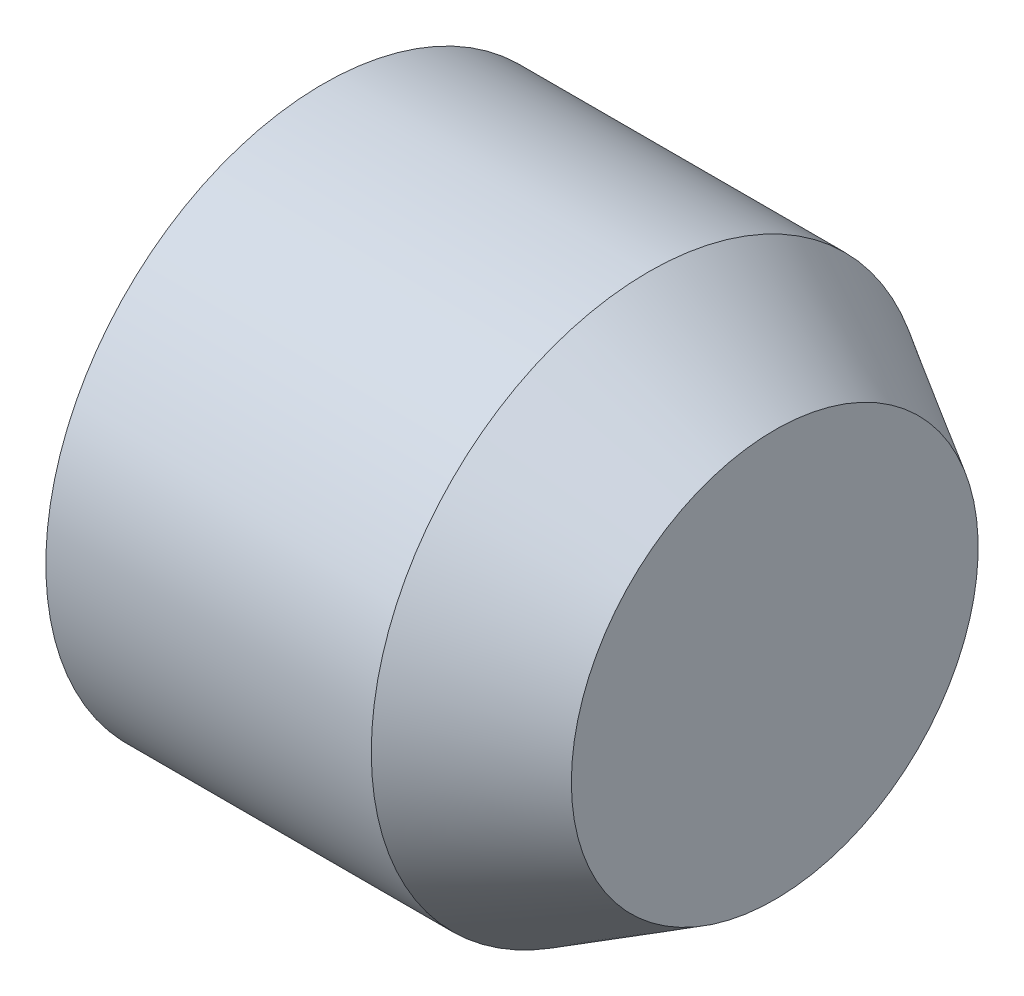
from build123d import *

# Parameters (mm, degrees)
SKETCH1_R           = 34.09
SKETCH1_R_2         = 32.09
BOSS_EXTRUDE1_DEPTH = 40
SWEEP1_PITCH        = 10
SWEEP1_HEIGHT       = 12.5
SWEEP1_RADIUS       = 32.09
SKETCH3_R           = 1.25
SKETCH4_R           = 34.09
CUT_EXTRUDE1_DEPTH  = 63.643884152
CHAMFER1_SIZE       = 1.2


with BuildPart() as part:
    # Sketch1 → Boss-Extrude1 (new body)
    with BuildSketch(Plane(origin=(0, 0, 0), x_dir=(0, 0, -1), z_dir=(1, 0, 0))):
        Circle(SKETCH1_R)
        Circle(SKETCH1_R_2, mode=Mode.SUBTRACT)
    extrude(amount=BOSS_EXTRUDE1_DEPTH)

    # Sweep1: sweep along a helix
    with BuildLine() as sweep1_path:
        Helix(SWEEP1_PITCH, SWEEP1_HEIGHT, SWEEP1_RADIUS, center=(0, 0, 0), direction=(1, 0, 0))
    # Sketch3 → Sweep1 (sweep)
    with BuildSketch(Plane(origin=(0, 0, 0), x_dir=(1, 0, 0), z_dir=(0, 1, 0))):
        with Locations((0, -32.09)):
            Circle(SKETCH3_R)
    sweep(path=sweep1_path.line, is_frenet=True)

    # Sketch4 → Cut-Extrude1 (cut, through all)
    with BuildSketch(Plane.ZY):
        with Locations(Location((0, 0, 0), (0, 0, 180))):
            Circle(SKETCH4_R)
    extrude(amount=CUT_EXTRUDE1_DEPTH, mode=Mode.SUBTRACT)

    # Chamfer1
    chamfer1_edges = [part.edges().sort_by_distance(p)[0] for p in [
        (0, 0, 31.465),
    ]]
    chamfer(chamfer1_edges, length=CHAMFER1_SIZE)

    # Sketch5 → Revolve1 (revolve)
    with BuildSketch(Plane(origin=(0, 0, 0), x_dir=(1, 0, 0), z_dir=(0, 1, 0)), mode=Mode.PRIVATE) as revolve1_sk:
        Polygon((55.5, 0), (55.5, 25), (40, 34.09), (40, 32.09), (53.5, 23), (53.5, 0), align=None)
    revolve(revolve1_sk.sketch.rotate(Axis((40, 0, 0), (1, 0, 0)), 180), axis=Axis((40, 0, 0), (1, 0, 0)))


solid = part.part
